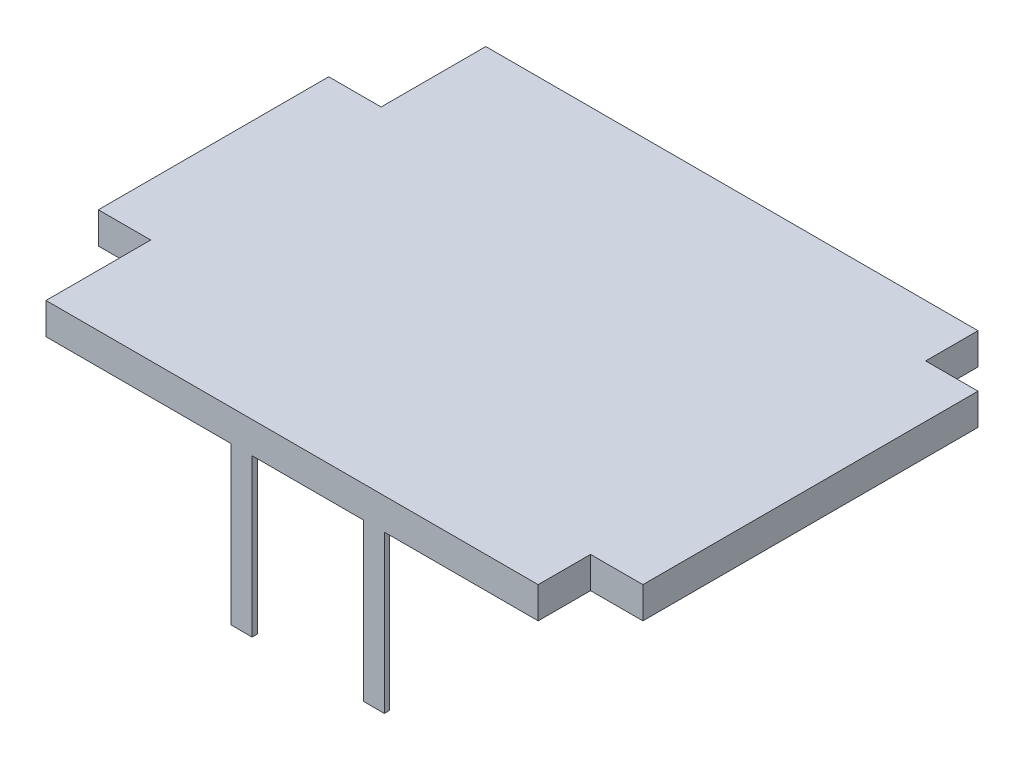
from build123d import *

# Parameters (mm, degrees)
BOSS_EXTRUDE1_DEPTH = 0.3
BOSS_EXTRUDE2_DEPTH = 0.05
SKETCH4_W           = 0.2
SKETCH4_H           = 0.05
BOSS_EXTRUDE3_DEPTH = 1.5


with BuildPart() as part:
    # Sketch1 → Boss-Extrude1 (new body)
    with BuildSketch(Plane(origin=(0, 0, 0), x_dir=(1, 0, 0), z_dir=(0, 1, 0))):
        Polygon((0, -1.1), (0.5, -1.1), (0.5, -0.1), (5.2, -0.1), (5.2, -0.6), (5.7, -0.6), (5.7, -3.8), (5.2, -3.8), (5.2, -4.3), (0.5, -4.3), (0.5, -3.3), (0, -3.3), align=None)
    extrude(amount=BOSS_EXTRUDE1_DEPTH)

    # Sketch2 → Boss-Extrude2 (add)
    with BuildSketch(Plane(origin=(0, 0, 0.1), x_dir=(-1, 0, 0), z_dir=(0, 0, -1))):
        Polygon((-3.731039035, 0), (-2.267900634, 0), (-2.267900634, -1.5), (-2.467900634, -1.5), (-2.467900634, -0.2), (-3.531039035, -0.2), (-3.531039035, -1.5), (-3.731039035, -1.5), align=None)
    extrude(amount=-BOSS_EXTRUDE2_DEPTH)

    # Sketch4 → Boss-Extrude3 (add)
    with BuildSketch(Plane.XZ):
        with Locations((2.367900634, 4.275)):
            Rectangle(SKETCH4_W, SKETCH4_H)
        with Locations((3.631039035, 4.275)):
            Rectangle(SKETCH4_W, SKETCH4_H)
    extrude(amount=BOSS_EXTRUDE3_DEPTH)


solid = part.part
